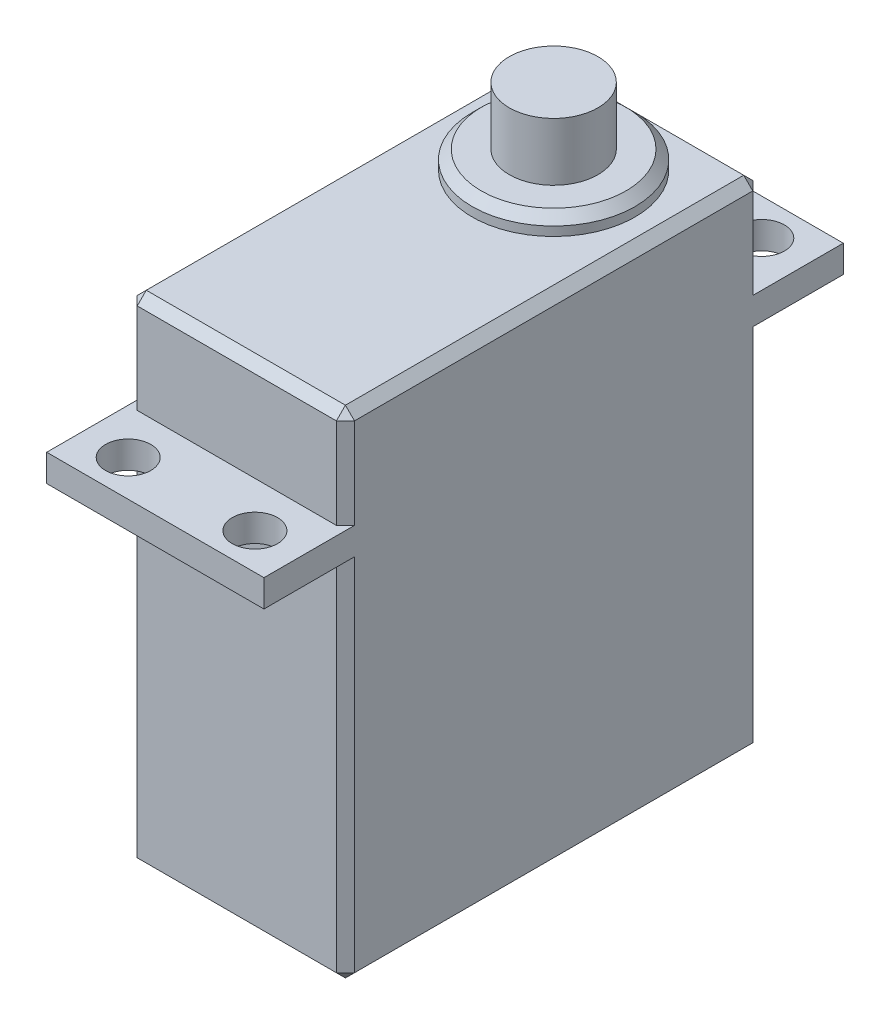
from build123d import *

# Parameters (mm, degrees)
SKETCH1_W           = 23
SKETCH1_H           = 27.4
SKETCH1_W_2         = 4.5
SKETCH1_H_2         = 1.5
BOSS_EXTRUDE1_DEPTH = 6
CHAMFER1_SIZE       = 0.5
SKETCH3_R           = 1.25
CUT_EXTRUDE1_DEPTH  = 28.4
BOSS_EXTRUDE2_START = -7
SKETCH3_3_R         = 4.5
BOSS_EXTRUDE2_DEPTH = 8
CHAMFER2_SIZE       = 0.5
BOSS_EXTRUDE3_START = 1
SKETCH3_4_R         = 2.45
BOSS_EXTRUDE3_DEPTH = 3.2


with BuildPart() as part:
    # Sketch1 → Boss-Extrude1 (new body, symmetric)
    with BuildSketch(Plane(origin=(0, 0, 0), x_dir=(0, 0, -1), z_dir=(1, 0, 0))):
        with Locations((-11.5, 13.7)):
            Rectangle(SKETCH1_W, SKETCH1_H)
        with Locations((-25.25, 21.15)):
            Rectangle(SKETCH1_W_2, SKETCH1_H_2)
        with Locations((2.25, 21.15)):
            Rectangle(SKETCH1_W_2, SKETCH1_H_2)
    extrude(amount=BOSS_EXTRUDE1_DEPTH, both=True)

    # Chamfer1
    chamfer1_edges = [part.edges().sort_by_distance(p)[0] for p in [
        (-6, 24.65, 23),
        (-6, 27.4, 11.5),
        (-6, 24.65, 0),
        (-6, 10.2, 0),
        (-6, 0, 11.5),
        (-6, 10.2, 23),
        (6, 10.2, 23),
        (0, 27.4, 23),
        (0, 27.4, 0),
        (0, 0, 0),
        (0, 0, 23),
        (6, 0, 11.5),
        (6, 10.2, 0),
        (6, 24.65, 0),
        (6, 27.4, 11.5),
        (6, 24.65, 23),
    ]]
    chamfer(chamfer1_edges, length=CHAMFER1_SIZE)

    # Sketch3 → Cut-Extrude1 (cut, through all)
    with BuildSketch(Plane(origin=(0, 27.4, 0), x_dir=(1, 0, 0), z_dir=(0, 1, 0))):
        with Locations((-3.5, -25.5)):
            Circle(SKETCH3_R)
        with Locations((3.5, -25.5)):
            Circle(SKETCH3_R)
        with Locations((3.5, 2.5)):
            Circle(SKETCH3_R)
        with Locations((-3.5, 2.5)):
            Circle(SKETCH3_R)
    extrude(amount=-CUT_EXTRUDE1_DEPTH, mode=Mode.SUBTRACT)

    # Sketch3_3 → Boss-Extrude2 (add)
    with BuildSketch(Plane(origin=(0, 27.4, 0), x_dir=(1, 0, 0), z_dir=(0, 1, 0)).offset(BOSS_EXTRUDE2_START)):
        with Locations((0, -5.5)):
            Circle(SKETCH3_3_R)
    extrude(amount=BOSS_EXTRUDE2_DEPTH)

    # Chamfer2
    chamfer2_edges = [part.edges().sort_by_distance(p)[0] for p in [
        (-4.5, 28.4, 5.5),
    ]]
    chamfer(chamfer2_edges, length=CHAMFER2_SIZE)

    # Sketch3_4 → Boss-Extrude3 (add)
    with BuildSketch(Plane(origin=(0, 27.4, 0), x_dir=(1, 0, 0), z_dir=(0, 1, 0)).offset(BOSS_EXTRUDE3_START)):
        with Locations((0, -5.5)):
            Circle(SKETCH3_4_R)
    extrude(amount=BOSS_EXTRUDE3_DEPTH)


solid = part.part
